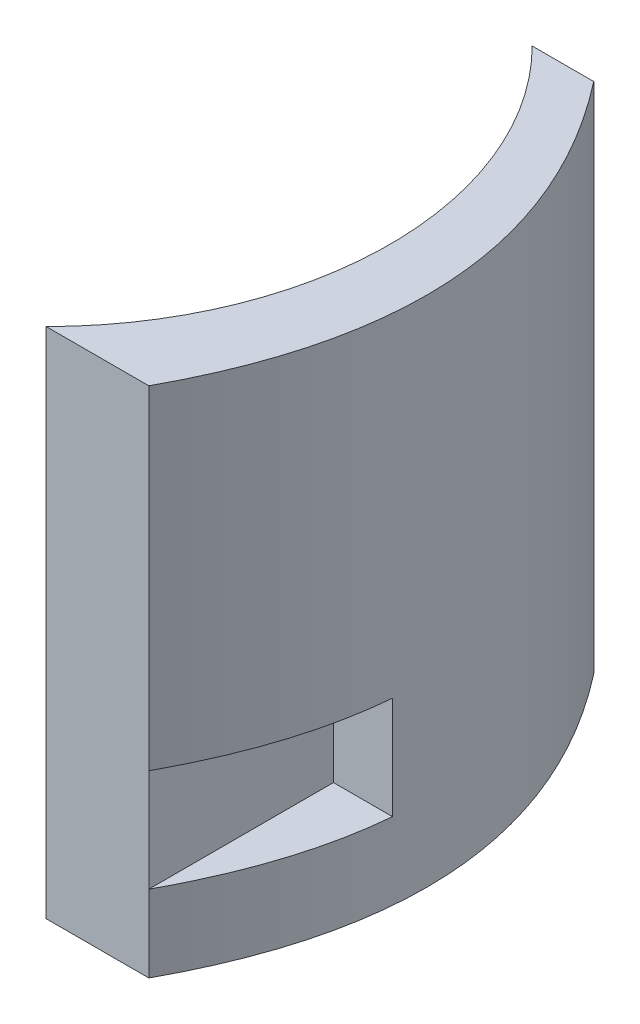
from build123d import *

# Parameters (mm, degrees)
BOSS_EXTRUDE1_DEPTH = 50
SKETCH3_W           = 6
SKETCH3_H           = 10
CUT_EXTRUDE1_DEPTH  = 18


with BuildPart() as part:
    # Sketch2 → Boss-Extrude1 (new body)
    with BuildSketch(Plane(origin=(0, 0, 0), x_dir=(1, 0, 0), z_dir=(0, 1, 0))):
        with BuildLine():
            Line((29.68807717, 23.68807717), (23.68807717, 23.68807717))
            ThreePointArc((23.68807717, 23.68807717), (30.949964339, 12.819894984), (33.5, 0))
            ThreePointArc((33.5, 0), (30.949964339, -12.819894984), (23.68807717, -23.68807717))
            Line((23.68807717, -23.68807717), (33.68807717, -23.68807717))
            add(Edge.make_bspline(
                [(29.68807717, 23.68807717), (47.221735333, 1.183613852), (33.68807717, -23.68807717)],
                knots=[0, 0, 0, 1, 1, 1], degree=2))
        make_face()
    extrude(amount=BOSS_EXTRUDE1_DEPTH)

    # Sketch3 → Cut-Extrude1 (cut)
    with BuildSketch(Plane.XY.offset(23.68807717)):
        with Locations((36.68807717, 12.5)):
            Rectangle(SKETCH3_W, SKETCH3_H)
    extrude(amount=-CUT_EXTRUDE1_DEPTH, mode=Mode.SUBTRACT)


solid = part.part
